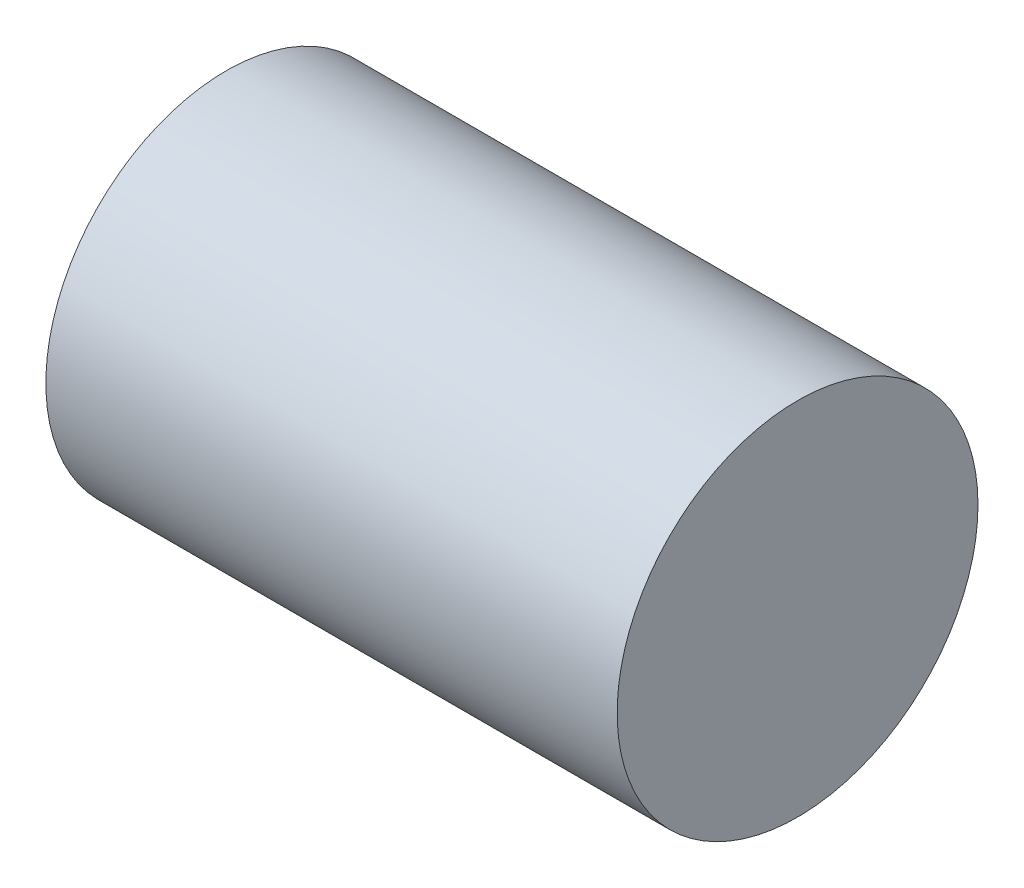
from build123d import *

# Parameters (mm, degrees)
SKETCH1_R           = 3
BOSS_EXTRUDE1_DEPTH = 9.5


with BuildPart() as part:
    # Sketch1 → Boss-Extrude1 (new body)
    with BuildSketch(Plane(origin=(0, 0, 0), x_dir=(0, 0, -1), z_dir=(1, 0, 0))):
        Circle(SKETCH1_R)
    extrude(amount=BOSS_EXTRUDE1_DEPTH)


solid = part.part
